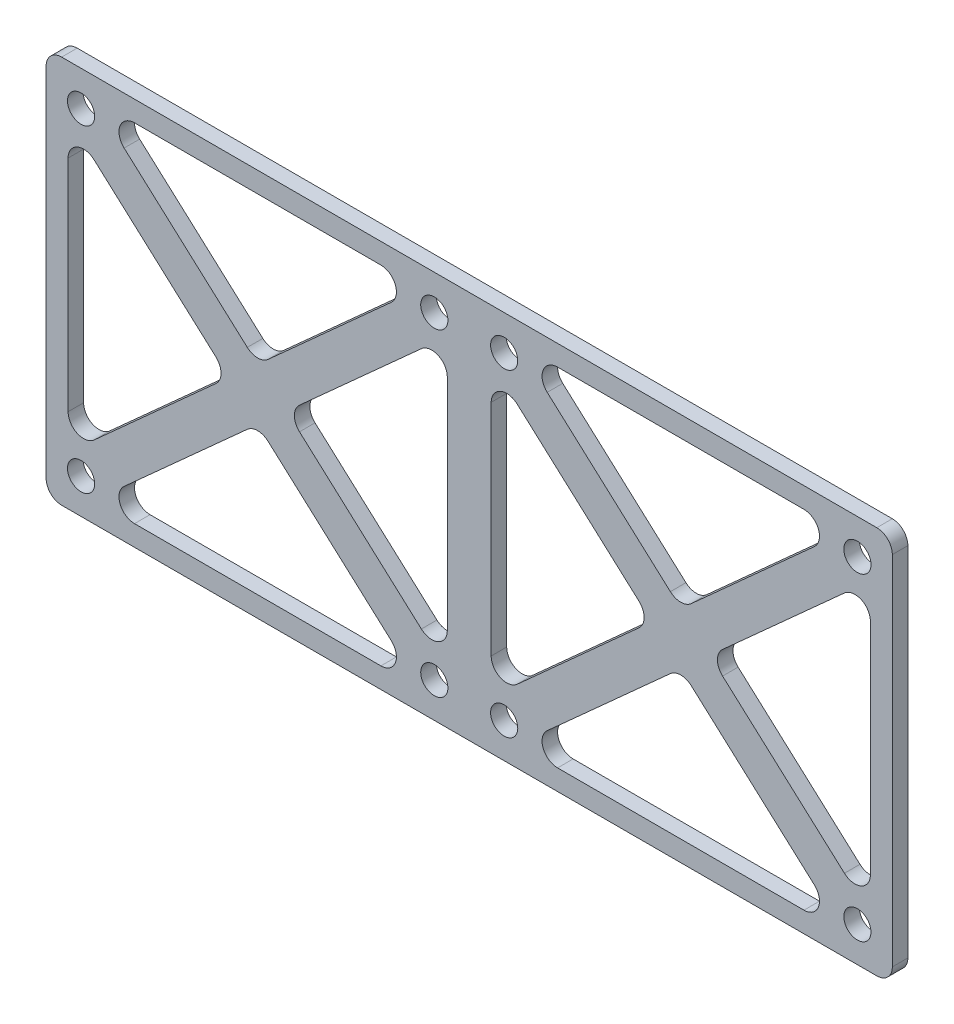
from build123d import *

# Parameters (mm, degrees)
SKETCH1_W           = 109
SKETCH1_H           = 50
SKETCH1_R           = 1.75
BOSS_EXTRUDE1_DEPTH = 2
FILLET1_R           = 2


with BuildPart() as part:
    # Sketch1 → Boss-Extrude1 (new body)
    with BuildSketch(Plane.XY):
        Rectangle(SKETCH1_W, SKETCH1_H)
        with Locations((-4.5, 20.5)):
            Circle(SKETCH1_R, mode=Mode.SUBTRACT)
        with Locations((-4.5, -20.5)):
            Circle(SKETCH1_R, mode=Mode.SUBTRACT)
        with Locations((-50, 20.5)):
            Circle(SKETCH1_R, mode=Mode.SUBTRACT)
        with Locations((-50, -20.5)):
            Circle(SKETCH1_R, mode=Mode.SUBTRACT)
        with Locations((50, -20.5)):
            Circle(SKETCH1_R, mode=Mode.SUBTRACT)
        with Locations((4.5, -20.5)):
            Circle(SKETCH1_R, mode=Mode.SUBTRACT)
        with Locations((4.5, 20.5)):
            Circle(SKETCH1_R, mode=Mode.SUBTRACT)
        with Locations((50, 20.5)):
            Circle(SKETCH1_R, mode=Mode.SUBTRACT)
        Polygon((-51.673539091, 18.642779789), (-30.984600544, 0), (-51.673539091, -18.642779789), align=None, mode=Mode.SUBTRACT)
        Polygon((-48.326460909, 22.357220211), (-27.25, 3.365244447), (-6.173539091, 22.357220211), align=None, mode=Mode.SUBTRACT)
        Polygon((-2.826460909, 18.642779789), (-2.826460909, -18.642779789), (-23.515399456, 0), align=None, mode=Mode.SUBTRACT)
        Polygon((-6.173539091, -22.357220211), (-48.326460909, -22.357220211), (-27.25, -3.365244447), align=None, mode=Mode.SUBTRACT)
        Polygon((6.173539091, -22.357220211), (48.326460909, -22.357220211), (27.25, -3.365244447), align=None, mode=Mode.SUBTRACT)
        Polygon((51.673539091, 18.642779789), (51.673539091, -18.642779789), (30.984600544, 0), align=None, mode=Mode.SUBTRACT)
        Polygon((48.326460909, 22.357220211), (6.173539091, 22.357220211), (27.25, 3.365244447), align=None, mode=Mode.SUBTRACT)
        Polygon((23.515399456, 0), (2.826460909, -18.642779789), (2.826460909, 18.642779789), align=None, mode=Mode.SUBTRACT)
    extrude(amount=BOSS_EXTRUDE1_DEPTH)

    # Fillet1
    fillet1_edges = [part.edges().sort_by_distance(p)[0] for p in [
        (27.25, 3.365244447, 1),
        (48.326460909, 22.357220211, 1),
        (6.173539091, 22.357220211, 1),
        (23.515399456, 0, 1),
        (2.826460909, 18.642779789, 1),
        (2.826460909, -18.642779789, 1),
        (-27.25, 3.365244447, 1),
        (-6.173539091, 22.357220211, 1),
        (-48.326460909, 22.357220211, 1),
        (-51.673539091, 18.642779789, 1),
        (-51.673539091, -18.642779789, 1),
        (-30.984600544, 0, 1),
        (-6.173539091, -22.357220211, 1),
        (-27.25, -3.365244447, 1),
        (-48.326460909, -22.357220211, 1),
        (-2.826460909, 18.642779789, 1),
        (-23.515399456, 0, 1),
        (-2.826460909, -18.642779789, 1),
        (54.5, -25, 1),
        (-54.5, -25, 1),
        (-54.5, 25, 1),
        (54.5, 25, 1),
        (27.25, -3.365244447, 1),
        (6.173539091, -22.357220211, 1),
        (48.326460909, -22.357220211, 1),
        (51.673539091, 18.642779789, 1),
        (30.984600544, 0, 1),
        (51.673539091, -18.642779789, 1),
    ]]
    fillet(fillet1_edges, radius=FILLET1_R)


solid = part.part
